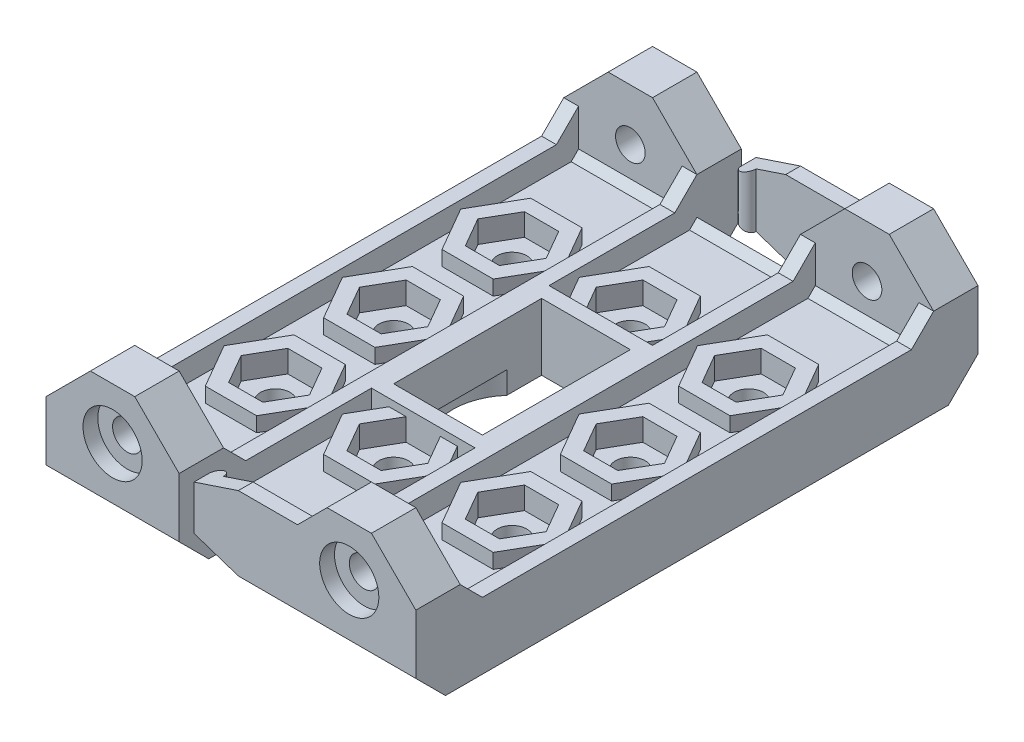
from build123d import *

# Parameters (mm, degrees)
SKETCH1_R                = 1.5
SKETCH1_R_2              = 1
SKETCH1_W                = 6
SKETCH1_H                = 10
EXTRUDE1_DEPTH           = 3
EXTRUDE2_DEPTH           = 4
EXTRUDE3_DEPTH           = 4
SKETCH7_W                = 1
SKETCH7_H                = 38
SKETCH7_W_2              = 6
SKETCH7_H_2              = 10
EXTRUDE4_DEPTH           = 4.5
EXTRUDE5_DEPTH           = 6
SKETCH9_R                = 5.5
SKETCH9_R_2              = 1.5
EXTRUDE10_DEPTH          = 3.5
EXTRUDE11_DEPTH          = 6
EXTRUDE12_DEPTH          = 4
CUT_EXTRUDE1_DEPTH       = 4
CUT_EXTRUDE2_DEPTH       = 4
SKETCH16_R               = 1
EXTRUDE13_DEPTH          = 3
CUT_EXTRUDE4_DEPTH       = 3
CUT_EXTRUDE5_DEPTH       = 10
CUT_EXTRUDE6_DEPTH       = 2
EXTRUDE14_DEPTH          = 25
EXTRUDE15_DEPTH          = 1
EXTRUDE17_DEPTH          = 1
EXTRUDE18_DEPTH          = 1
EXTRUDE19_DEPTH          = 1
CUT_EXTRUDE7_DEPTH       = 37.5
SKETCH26_R               = 2
CUT_EXTRUDE8_DEPTH       = 1
SKETCH27_R               = 4
CUT_EXTRUDE9_DEPTH       = 1.5
SKETCH28_R               = 4
CUT_EXTRUDE10_DEPTH      = 1
CUT_EXTRUDE11_DEPTH      = 1.5
FILLET4_R                = 0.25
CUT_EXTRUDE12_DEPTH      = 1.5
SKETCH31_W               = 16.002833782
SKETCH31_H               = 38
CUT_EXTRUDE13_DEPTH      = 10
CUT_EXTRUDE14_DEPTH      = 14.5
CUT_EXTRUDE14_DEPTH_BACK = 14.5
EXTRUDE20_DEPTH          = 15
EXTRUDE20_DEPTH_BACK     = 15
EXTRUDE21_DEPTH          = 1
CUT_EXTRUDE15_DEPTH      = 0.5
SKETCH36_R               = 1
CUT_EXTRUDE16_DEPTH      = 10.5


with BuildPart() as part:
    # Sketch1 → Extrude1 (new body)
    with BuildSketch(Plane(origin=(0, 0, 0), x_dir=(1, 0, 0), z_dir=(0, 1, 0))):
        with BuildLine():
            Line((-12.5, -19), (-12.5, -12.75))
            ThreePointArc((-12.5, -12.75), (-13.085786438, -11.335786438), (-14.5, -10.75))
            Line((-14.5, -10.75), (-19, -10.75))
            ThreePointArc((-19, -10.75), (-22.535533906, -9.285533906), (-24, -5.75))
            Line((-24, -5.75), (-24, 5.75))
            ThreePointArc((-24, 5.75), (-22.535533906, 9.285533906), (-19, 10.75))
            Line((-19, 10.75), (-14.5, 10.75))
            ThreePointArc((-14.5, 10.75), (-13.085786438, 11.335786438), (-12.5, 12.75))
            Line((-12.5, 12.75), (-12.5, 19))
            Line((-12.5, 19), (12.5, 19))
            Line((12.5, 19), (12.5, -19))
            Line((12.5, -19), (-12.5, -19))
        make_face()
        with Locations((-14.5, 0)):
            Circle(SKETCH1_R, mode=Mode.SUBTRACT)
        with Locations((0, 8)):
            Circle(SKETCH1_R_2, mode=Mode.SUBTRACT)
        with Locations((8, 0)):
            Circle(SKETCH1_R_2, mode=Mode.SUBTRACT)
        with Locations((0, -8)):
            Circle(SKETCH1_R_2, mode=Mode.SUBTRACT)
        with Locations((-8, 0)):
            Circle(SKETCH1_R_2, mode=Mode.SUBTRACT)
        with Locations((-20.156854249, 5.656854249)):
            Circle(SKETCH1_R_2, mode=Mode.SUBTRACT)
        with Locations((-20.156854249, -5.656854249)):
            Circle(SKETCH1_R_2, mode=Mode.SUBTRACT)
        with Locations((-8.843145751, -5.656854249)):
            Circle(SKETCH1_R_2, mode=Mode.SUBTRACT)
        with Locations((-8.843145751, 5.656854249)):
            Circle(SKETCH1_R_2, mode=Mode.SUBTRACT)
        with Locations((8, 8)):
            Circle(SKETCH1_R_2, mode=Mode.SUBTRACT)
        with Locations((8, -8)):
            Circle(SKETCH1_R_2, mode=Mode.SUBTRACT)
        Rectangle(SKETCH1_W, SKETCH1_H, mode=Mode.SUBTRACT)
    extrude(amount=EXTRUDE1_DEPTH)

    # Sketch2 → Extrude2 (add)
    with BuildSketch(Plane(origin=(0, 0, 0), x_dir=(1, 0, 0), z_dir=(0, 1, 0))):
        Polygon((-19.260278777, -2.310789035), (-16.810789035, -4.760278777), (-17.707364507, -8.106343992), (-21.053429722, -9.002919464), (-23.502919464, -6.553429722), (-22.606343992, -3.207364507), align=None)
        Polygon((-19.559663372, -3.426127712), (-17.926258803, -5.058709362), (-18.523413702, -7.289570039), (-20.75397317, -7.887849066), (-22.387377739, -6.255267415), (-21.79022284, -4.024406738), align=None, mode=Mode.SUBTRACT)
        Polygon((-6.393656008, 3.207364507), (-9.739721223, 2.310789035), (-12.189210965, 4.760278777), (-11.292635493, 8.106343992), (-7.946570278, 9.002919464), (-5.497080536, 6.553429722), align=None)
        Polygon((-7.210429961, 4.023413702), (-9.441290638, 3.426258803), (-11.073872288, 5.059663372), (-10.475593262, 7.29022284), (-8.244732585, 7.887377739), (-6.612150934, 6.25397317), align=None, mode=Mode.SUBTRACT)
        Polygon((-16.810789035, 4.760278777), (-19.260278777, 2.310789035), (-22.606343992, 3.207364507), (-23.502919464, 6.553429722), (-21.053429722, 9.002919464), (-17.707364507, 8.106343992), align=None)
        Polygon((-17.926127712, 5.059663372), (-19.558709362, 3.426258803), (-21.789570039, 4.023413702), (-22.387849066, 6.25397317), (-20.755267415, 7.887377739), (-18.524406738, 7.29022284), align=None, mode=Mode.SUBTRACT)
        Polygon((-12.189210965, -4.760278777), (-9.739721223, -2.310789035), (-6.393656008, -3.207364507), (-5.497080536, -6.553429722), (-7.946570278, -9.002919464), (-11.292635493, -8.106343992), align=None)
        Polygon((-11.073872288, -5.059663372), (-9.441290638, -3.426258803), (-7.210429961, -4.023413702), (-6.612150934, -6.25397317), (-8.244732585, -7.887377739), (-10.475593262, -7.29022284), align=None, mode=Mode.SUBTRACT)
    extrude(amount=EXTRUDE2_DEPTH)

    # Sketch5 → Extrude3 (add)
    with BuildSketch(Plane(origin=(0, 0, 0), x_dir=(1, 0, 0), z_dir=(0, 1, 0))):
        Polygon((-3.464101615, -8), (-1.732050808, -11), (1.732050808, -11), (3.464101615, -8), (1.732050808, -5), (-1.732050808, -5), align=None)
        Polygon((-2.309401077, -8), (-1.154700538, -10), (1.154700538, -10), (2.309401077, -8), (1.154700538, -6), (-1.154700538, -6), align=None, mode=Mode.SUBTRACT)
        Polygon((-1.732050808, 11), (1.732050808, 11), (3.464101615, 8), (1.732050808, 5), (-1.732050808, 5), (-3.464101615, 8), align=None)
        Polygon((-1.154700538, 10), (1.154700538, 10), (2.309401077, 8), (1.154700538, 6), (-1.154700538, 6), (-2.309401077, 8), align=None, mode=Mode.SUBTRACT)
        Polygon((11.464101615, 8), (9.732050808, 11), (6.267949192, 11), (4.535898385, 8), (6.267949192, 5), (9.732050808, 5), align=None)
        Polygon((10.309401077, 8), (9.154700538, 10), (6.845299462, 10), (5.690598923, 8), (6.845299462, 6), (9.154700538, 6), align=None, mode=Mode.SUBTRACT)
        Polygon((9.732050808, -11), (6.267949192, -11), (4.535898385, -8), (6.267949192, -5), (9.732050808, -5), (11.464101615, -8), align=None)
        Polygon((9.154700538, -10), (6.845299462, -10), (5.690598923, -8), (6.845299462, -6), (9.154700538, -6), (10.309401077, -8), align=None, mode=Mode.SUBTRACT)
        Polygon((9.732050808, -3), (6.267949192, -3), (4.535898385, 0), (6.267949192, 3), (9.732050808, 3), (11.464101615, 0), align=None)
        Polygon((9.154700538, -2), (6.845299462, -2), (5.690598923, 0), (6.845299462, 2), (9.154700538, 2), (10.309401077, 0), align=None, mode=Mode.SUBTRACT)
        Polygon((-11, -1.732050808), (-11, 1.732050808), (-8, 3.464101615), (-5, 1.732050808), (-5, -1.732050808), (-8, -3.464101615), align=None)
        Polygon((-10, -1.154700538), (-10, 1.154700538), (-8, 2.309401077), (-6, 1.154700538), (-6, -1.154700538), (-8, -2.309401077), align=None, mode=Mode.SUBTRACT)
    extrude(amount=EXTRUDE3_DEPTH)

    # Sketch7 → Extrude4 (add)
    with BuildSketch(Plane(origin=(0, 0, 0), x_dir=(1, 0, 0), z_dir=(0, 1, 0))):
        with Locations((-12, 0)):
            Rectangle(SKETCH7_W, SKETCH7_H)
        Polygon((-4.5, 19), (-3.5, 19), (-3.5, 6), (3.5, 6), (3.5, 19), (4.5, 19), (4.5, -19), (3.5, -19), (3.5, -6), (-3.5, -6), (-3.5, -19), (-4.5, -19), align=None)
        Rectangle(SKETCH7_W_2, SKETCH7_H_2, mode=Mode.SUBTRACT)
        with Locations((12, 0)):
            Rectangle(SKETCH7_W, SKETCH7_H)
    extrude(amount=EXTRUDE4_DEPTH)

    # Sketch8 → Extrude5 (add)
    with BuildSketch(Plane(origin=(0, 0, 0), x_dir=(1, 0, 0), z_dir=(0, 1, 0))):
        with BuildLine():
            Line((-11.5, -9.748913396), (-11.5, -10.25))
            ThreePointArc((-11.5, -10.25), (-11.646446609, -10.603553391), (-12, -10.75))
            Line((-12, -10.75), (-19, -10.75))
            ThreePointArc((-19, -10.75), (-22.535533906, -9.285533906), (-24, -5.75))
            Line((-24, -5.75), (-24, 5.751086604))
            ThreePointArc((-24, 5.751086604), (-22.535533906, 9.28662051), (-19, 10.751086604))
            Line((-19, 10.751086604), (-12, 10.751086604))
            ThreePointArc((-12, 10.751086604), (-11.646446609, 10.604639995), (-11.5, 10.251086604))
            Line((-11.5, 10.251086604), (-11.5, 9.751086604))
            ThreePointArc((-11.5, 9.751086604), (-11.646446609, 9.397533214), (-12, 9.251086604))
            Line((-12, 9.251086604), (-19, 9.251086604))
            ThreePointArc((-19, 9.251086604), (-21.474873734, 8.225960339), (-22.5, 5.751086604))
            Line((-22.5, 5.751086604), (-22.5, -5.748913396))
            ThreePointArc((-22.5, -5.748913396), (-21.474873734, -8.22378713), (-19, -9.248913396))
            Line((-19, -9.248913396), (-12, -9.248913396))
            ThreePointArc((-12, -9.248913396), (-11.646446609, -9.395360005), (-11.5, -9.748913396))
        make_face()
    extrude(amount=EXTRUDE5_DEPTH)

    # Sketch9 → Extrude10 (add)
    with BuildSketch(Plane(origin=(0, 0, 0), x_dir=(1, 0, 0), z_dir=(0, 1, 0))):
        with Locations((-14.5, 0)):
            Circle(SKETCH9_R)
        with Locations((-14.5, 0)):
            Circle(SKETCH9_R_2, mode=Mode.SUBTRACT)
    extrude(amount=EXTRUDE10_DEPTH)

    # Sketch10 → Extrude11 (add)
    with BuildSketch(Plane(origin=(0, 0, 0), x_dir=(1, 0, 0), z_dir=(0, 1, 0))):
        Polygon((-16.953738644, 4.25), (-12.046261356, 4.25), (-9.592522712, 0), (-12.046261356, -4.25), (-16.953738644, -4.25), (-19.407477288, 0), align=None)
        Polygon((-16.232050808, 3), (-12.767949192, 3), (-11.035898385, 0), (-12.767949192, -3), (-16.232050808, -3), (-17.964101615, 0), align=None, mode=Mode.SUBTRACT)
    extrude(amount=EXTRUDE11_DEPTH)

    # Sketch12 → Extrude12 (add)
    with BuildSketch(Plane(origin=(0, 0, 0), x_dir=(1, 0, 0), z_dir=(0, 1, 0))):
        with BuildLine():
            Line((-11.5, 4.609772229), (-11.5, -4.609772229))
            ThreePointArc((-11.5, -4.609772229), (-9, 0), (-11.5, 4.609772229))
        make_face()
    extrude(amount=EXTRUDE12_DEPTH)

    # Sketch13 → Cut-Extrude1 (cut)
    with BuildSketch(Plane(origin=(0, 3.5, 0), x_dir=(-1, 0, 0), z_dir=(0, 1, 0))):
        Polygon((11.035898385, 0), (12.767949192, 3), (16.232050808, 3), (17.964101615, 0), (16.232050808, -3), (12.767949192, -3), align=None)
    extrude(amount=CUT_EXTRUDE1_DEPTH, mode=Mode.SUBTRACT)

    # Sketch14 → Cut-Extrude2 (cut)
    with BuildSketch(Plane(origin=(0, 3, 0), x_dir=(-1, 0, 0), z_dir=(0, 1, 0))):
        Polygon((8, -2.309401077), (10, -1.154700538), (10, 1.154700538), (8, 2.309401077), align=None)
    extrude(amount=CUT_EXTRUDE2_DEPTH, mode=Mode.SUBTRACT)

    # Sketch16 → Extrude13 (add)
    with BuildSketch(Plane.XY.offset(19)):
        Polygon((12.5, 0), (12.5, 6), (9.5, 9), (6.5, 9), (4.5, 7), (0.5, 7), (-2.5, 6), (-2.5, 3), (0.5, 2), (3.5, 2), (3.5, 0), align=None)
        with Locations((8, 5.5)):
            Circle(SKETCH16_R, mode=Mode.SUBTRACT)
        Polygon((-6.5, 9), (-3.5, 6), (-3.5, 0), (-12.5, 0), (-12.5, 6), (-9.5, 9), align=None)
        with Locations((-8, 5.5)):
            Circle(SKETCH16_R, mode=Mode.SUBTRACT)
    extrude13 = extrude(amount=-EXTRUDE13_DEPTH)

    # Sketch17 → Cut-Extrude4 (cut)
    with BuildSketch(Plane.XY.offset(19)):
        Polygon((-2.5, 3), (0.5, 2), (4.5, 2), (4.5, 0), (-3.5, 0), (-3.5, 3), align=None)
    cut_extrude4 = extrude(amount=-CUT_EXTRUDE4_DEPTH, mode=Mode.SUBTRACT)

    # Sketch18 → Cut-Extrude5 (cut, through all)
    with BuildSketch(Plane(origin=(0, 0, 0), x_dir=(1, 0, 0), z_dir=(0, 1, 0))):
        with BuildLine():
            Line((-2.5, -16), (3.5, -16))
            Line((3.5, -16), (3.5, -18))
            Line((3.5, -18), (-1.5, -18))
            ThreePointArc((-1.5, -18), (-2, -17.5), (-2.5, -18))
            Line((-2.5, -18), (-2.5, -16))
        make_face()
    cut_extrude5 = extrude(amount=CUT_EXTRUDE5_DEPTH, mode=Mode.SUBTRACT)

    # Sketch19 → Cut-Extrude6 (cut)
    with BuildSketch(Plane(origin=(0, 0, 16), x_dir=(-1, 0, 0), z_dir=(0, 0, -1))):
        Polygon((-4.5, 7), (-3.5, 6), (-3.5, 7), align=None)
    cut_extrude6 = extrude(amount=-CUT_EXTRUDE6_DEPTH, mode=Mode.SUBTRACT)

    # Sketch20 → Extrude14 (add)
    with BuildSketch(Plane(origin=(12.5, 0, 0), x_dir=(0, 0, -1), z_dir=(1, 0, 0))):
        Polygon((-16, 3), (-15.5, 3), (-16, 3.5), align=None)
    extrude14 = extrude(amount=-EXTRUDE14_DEPTH)

    # Sketch21 → Extrude15 (add)
    with BuildSketch(Plane(origin=(12.5, 0, 0), x_dir=(0, 0, -1), z_dir=(1, 0, 0))):
        Polygon((-16, 6), (-14.5, 4.5), (-16, 4.5), align=None)
    extrude15 = extrude(amount=-EXTRUDE15_DEPTH)

    # Sketch22 → Extrude17 (add)
    with BuildSketch(Plane(origin=(4.5, 0, 0), x_dir=(0, 0, -1), z_dir=(1, 0, 0))):
        Polygon((-16, 6), (-14.5, 4.5), (-16, 4.5), align=None)
    extrude17 = extrude(amount=-EXTRUDE17_DEPTH)

    # Sketch23 → Extrude18 (add)
    with BuildSketch(Plane(origin=(-3.5, 0, 0), x_dir=(0, 0, -1), z_dir=(1, 0, 0))):
        Polygon((-16, 6), (-14.5, 4.5), (-16, 4.5), align=None)
    extrude18 = extrude(amount=-EXTRUDE18_DEPTH)

    # Sketch24 → Extrude19 (add)
    with BuildSketch(Plane(origin=(-11.5, 0, 0), x_dir=(0, 0, -1), z_dir=(1, 0, 0))):
        Polygon((-16, 6), (-14.5, 4.5), (-16, 4.5), align=None)
    extrude19 = extrude(amount=-EXTRUDE19_DEPTH)

    # Sketch25 → Cut-Extrude7 (cut, through all)
    with BuildSketch(Plane(origin=(12.5, 0, 0), x_dir=(0, 0, -1), z_dir=(1, 0, 0))):
        Polygon((-19, 0), (-17, 0), (-19, 2), align=None)
    cut_extrude7 = extrude(amount=-CUT_EXTRUDE7_DEPTH, mode=Mode.SUBTRACT)

    # Sketch26 → Cut-Extrude8 (cut)
    with BuildSketch(Plane.XY.offset(19)):
        with Locations((-8, 5.5)):
            Circle(SKETCH26_R)
        with Locations((8, 5.5)):
            Circle(SKETCH26_R)
    cut_extrude8 = extrude(amount=-CUT_EXTRUDE8_DEPTH, mode=Mode.SUBTRACT)

    # Mirror1: Extrude13, Cut-Extrude4, Cut-Extrude5, Cut-Extrude6, Extrude14, Extrude15, Extrude17, Extrude18, Extrude19, Cut-Extrude7, Cut-Extrude8 across plane
    add(extrude13.mirror(Plane.XY))
    add(cut_extrude4.mirror(Plane.XY), mode=Mode.SUBTRACT)
    add(cut_extrude5.mirror(Plane.XY), mode=Mode.SUBTRACT)
    add(cut_extrude6.mirror(Plane.XY), mode=Mode.SUBTRACT)
    add(extrude14.mirror(Plane.XY))
    add(extrude15.mirror(Plane.XY))
    add(extrude17.mirror(Plane.XY))
    add(extrude18.mirror(Plane.XY))
    add(extrude19.mirror(Plane.XY))
    add(cut_extrude7.mirror(Plane.XY), mode=Mode.SUBTRACT)
    add(cut_extrude8.mirror(Plane.XY), mode=Mode.SUBTRACT)

    # Sketch27 → Cut-Extrude9 (cut)
    with BuildSketch(Plane.XZ):
        Circle(SKETCH27_R)
    extrude(amount=-CUT_EXTRUDE9_DEPTH, mode=Mode.SUBTRACT)

    # Sketch28 → Cut-Extrude10 (cut)
    with BuildSketch(Plane.XZ):
        with Locations((-14.5, 0)):
            Circle(SKETCH28_R)
    extrude(amount=-CUT_EXTRUDE10_DEPTH, mode=Mode.SUBTRACT)

    # Sketch29 → Cut-Extrude11 (cut)
    with BuildSketch(Plane.ZY.offset(24)):
        with BuildLine():
            Line((-2.500543302, 6), (2.499456698, 6))
            ThreePointArc((2.499456698, 6), (1.91367026, 4.585786438), (0.499456698, 4))
            Line((0.499456698, 4), (-0.500543302, 4))
            ThreePointArc((-0.500543302, 4), (-1.914756865, 4.585786438), (-2.500543302, 6))
        make_face()
    extrude(amount=-CUT_EXTRUDE11_DEPTH, mode=Mode.SUBTRACT)

    # Fillet4
    fillet4_edges = [part.edges().sort_by_distance(p)[0] for p in [
        (-11.023130678, 6, -2.477885683),
        (-10, 6, 0),
        (-14.5, 6, -4.25),
        (-18.180607966, 6, -2.125),
        (-18.180607966, 6, 2.125),
        (-14.5, 6, 4.25),
        (-11.023130678, 6, 2.477885683),
        (-17.098076211, 6, -1.5),
        (-17.098076211, 6, 1.5),
        (-14.5, 6, 3),
        (-11.901923789, 6, 1.5),
        (-11.901923789, 6, -1.5),
        (-14.5, 6, -3),
    ]]
    fillet(fillet4_edges, radius=FILLET4_R)

    # Sketch30 → Cut-Extrude12 (cut)
    with BuildSketch(Plane(origin=(0, 3.5, 0), x_dir=(-1, 0, 0), z_dir=(0, 1, 0))):
        Polygon((16.232050808, -3), (12.767949192, -3), (11.035898385, 0), (12.767949192, 3), (16.232050808, 3), (17.964101615, 0), align=None)
    extrude(amount=-CUT_EXTRUDE12_DEPTH, mode=Mode.SUBTRACT)

    # Sketch31 → Cut-Extrude13 (cut, through all)
    with BuildSketch(Plane.XZ):
        with Locations((-20.501416891, 0)):
            Rectangle(SKETCH31_W, SKETCH31_H)
    extrude(amount=-CUT_EXTRUDE13_DEPTH, mode=Mode.SUBTRACT)

    # Sketch32 → Cut-Extrude14 (cut, two sides)
    with BuildSketch(Plane(origin=(0, 0, 0), x_dir=(-1, 0, 0), z_dir=(0, 0, -1))) as cut_extrude14_sk:
        Polygon((12.837931972, 9.642365277), (4.5, 4.5), (4.5, 3), (11.5, 3), (11.5, 4.5), (12.837931972, 4.5), align=None)
    extrude(amount=CUT_EXTRUDE14_DEPTH, mode=Mode.SUBTRACT)
    extrude(cut_extrude14_sk.sketch, amount=-CUT_EXTRUDE14_DEPTH_BACK, mode=Mode.SUBTRACT)

    # Sketch33 → Extrude20 (add, two sides)
    with BuildSketch(Plane.XY) as extrude20_sk:
        Polygon((-4.5, 0), (-12.5, 0), (-12.5, 4.5), (-11.5, 4.5), (-11.5, 3), (-4.5, 3), align=None)
    extrude(amount=EXTRUDE20_DEPTH)
    extrude(extrude20_sk.sketch, amount=-EXTRUDE20_DEPTH_BACK)

    # Sketch34 → Extrude21 (add)
    with BuildSketch(Plane(origin=(0, 3, 0), x_dir=(-1, 0, 0), z_dir=(0, 1, 0))):
        Polygon((6.267949192, 5), (4.535898385, 8), (6.267949192, 11), (9.732050808, 11), (11.464101615, 8), (9.732050808, 5), align=None)
        Polygon((6.845299462, 6), (5.690598923, 8), (6.845299462, 10), (9.154700538, 10), (10.309401077, 8), (9.154700538, 6), align=None, mode=Mode.SUBTRACT)
        Polygon((6.267949192, -3), (4.535898385, 0), (6.267949192, 3), (9.732050808, 3), (11.464101615, 0), (9.732050808, -3), align=None)
        Polygon((6.845299462, -2), (5.690598923, 0), (6.845299462, 2), (9.154700538, 2), (10.309401077, 0), (9.154700538, -2), align=None, mode=Mode.SUBTRACT)
        Polygon((6.267949192, -11), (4.535898385, -8), (6.267949192, -5), (9.732050808, -5), (11.464101615, -8), (9.732050808, -11), align=None)
        Polygon((6.845299462, -10), (5.690598923, -8), (6.845299462, -6), (9.154700538, -6), (10.309401077, -8), (9.154700538, -10), align=None, mode=Mode.SUBTRACT)
    extrude(amount=EXTRUDE21_DEPTH)

    # Sketch35 → Cut-Extrude15 (cut)
    with BuildSketch(Plane(origin=(0, 3, 0), x_dir=(-1, 0, 0), z_dir=(0, 1, 0))):
        Polygon((10.309401077, -8), (9.154700538, -6), (6.845299462, -6), (5.690598923, -8), (6.845299462, -10), (9.154700538, -10), align=None)
        Polygon((10.309401077, 0), (9.154700538, 2), (6.845299462, 2), (5.690598923, 0), (6.845299462, -2), (9.154700538, -2), align=None)
        Polygon((-2.309401077, -8), (-1.154700538, -6), (1.154700538, -6), (2.309401077, -8), (1.154700538, -10), (-1.154700538, -10), align=None)
        Polygon((10.309401077, 8), (9.154700538, 10), (6.845299462, 10), (5.690598923, 8), (6.845299462, 6), (9.154700538, 6), align=None)
        Polygon((-1.154700538, 6), (1.154700538, 6), (2.309401077, 8), (1.154700538, 10), (-1.154700538, 10), (-2.309401077, 8), align=None)
        Polygon((-5.690598923, 0), (-6.845299462, -2), (-9.154700538, -2), (-10.309401077, 0), (-9.154700538, 2), (-6.845299462, 2), align=None)
        Polygon((-9.154700538, 6), (-10.309401077, 8), (-9.154700538, 10), (-6.845299462, 10), (-5.690598923, 8), (-6.845299462, 6), align=None)
        Polygon((-9.154700538, -10), (-10.309401077, -8), (-9.154700538, -6), (-6.845299462, -6), (-5.690598923, -8), (-6.845299462, -10), align=None)
    extrude(amount=-CUT_EXTRUDE15_DEPTH, mode=Mode.SUBTRACT)

    # Sketch36 → Cut-Extrude16 (cut)
    with BuildSketch(Plane.XZ):
        with Locations((-8, 8)):
            Circle(SKETCH36_R)
        with Locations((-8, 0)):
            Circle(SKETCH36_R)
        with Locations((-8, -8)):
            Circle(SKETCH36_R)
    extrude(amount=-CUT_EXTRUDE16_DEPTH, mode=Mode.SUBTRACT)


solid = part.part
